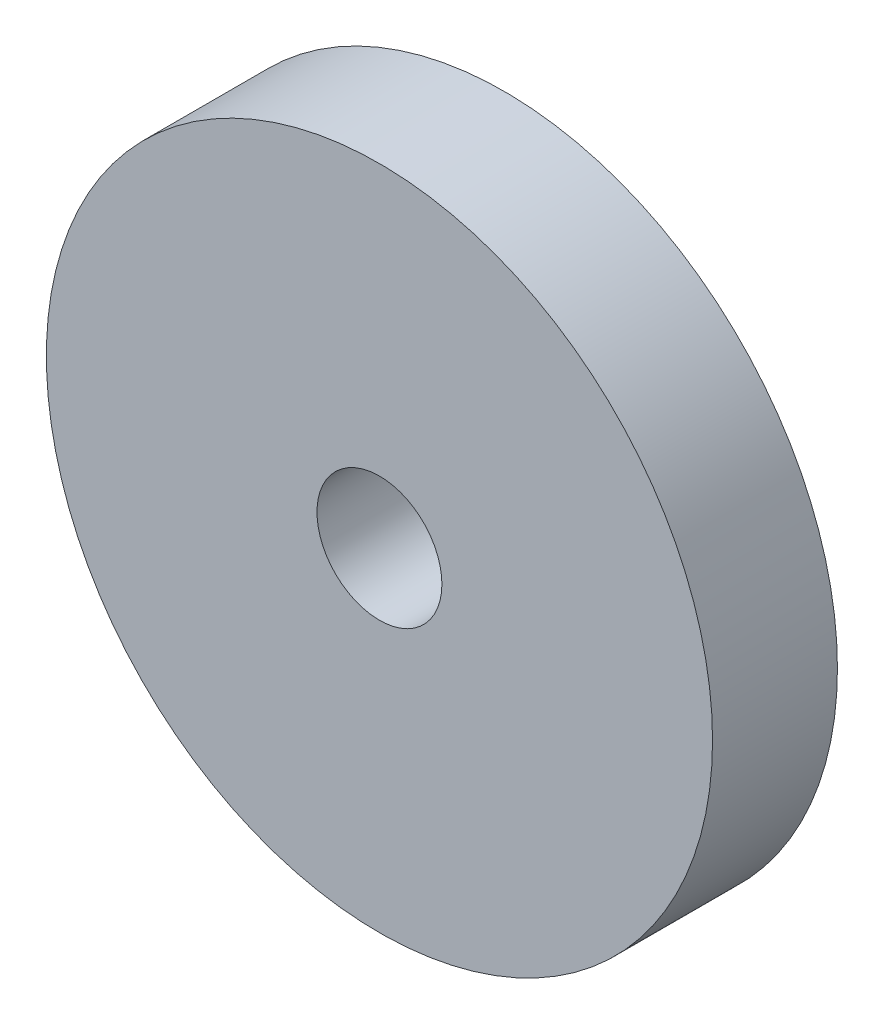
from build123d import *

# Parameters (mm, degrees)
SKETCH1_R           = 50.8
SKETCH1_R_2         = 9.525
BOSS_EXTRUDE1_DEPTH = 19.05


with BuildPart() as part:
    # Sketch1 → Boss-Extrude1 (new body)
    with BuildSketch(Plane.XY):
        Circle(SKETCH1_R)
        Circle(SKETCH1_R_2, mode=Mode.SUBTRACT)
    extrude(amount=BOSS_EXTRUDE1_DEPTH)


solid = part.part
